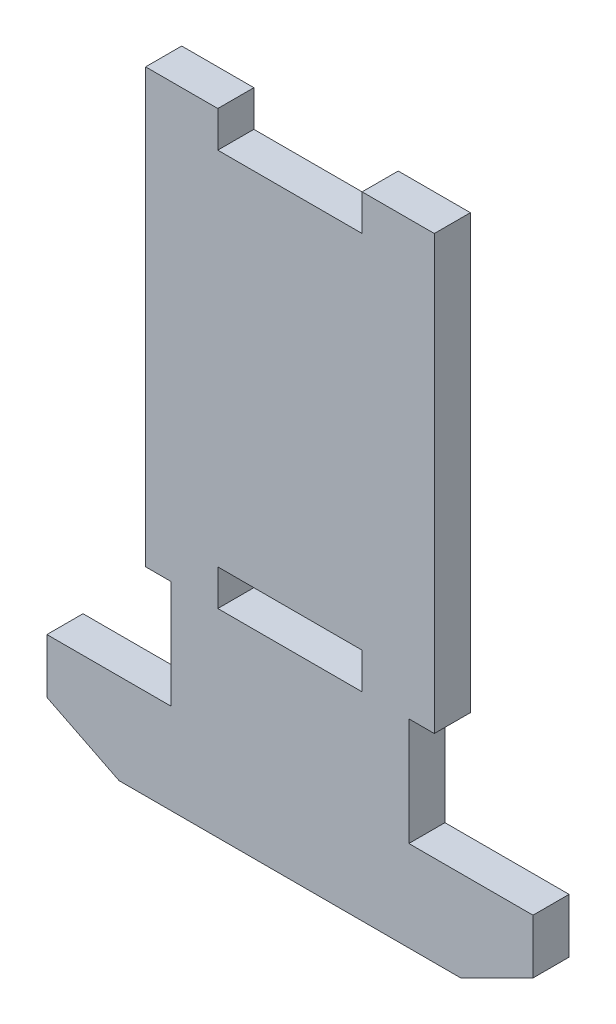
from build123d import *

# Parameters (mm, degrees)
BOSS_EXTRUDE1_DEPTH = 3.175
SKETCH2_W           = 25.4
SKETCH2_H           = 17.4625
BOSS_EXTRUDE2_DEPTH = 3.175
SKETCH4_W           = 2.238000096
SKETCH4_H           = 9.5
CUT_EXTRUDE1_DEPTH  = 3.175
SKETCH5_W           = 8.68426
SKETCH5_H           = 7.9625
BOSS_EXTRUDE3_DEPTH = 3.175
CUT_EXTRUDE2_DEPTH  = 3.175


with BuildPart() as part:
    # Sketch1 → Boss-Extrude1 (new body)
    with BuildSketch(Plane.XY):
        Polygon((-12.7, 19.05), (-6.35, 19.05), (-6.35, 15.875), (6.35, 15.875), (6.35, 19.05), (12.7, 19.05), (12.7, -19.05), (6.35, -19.05), (6.35, -15.875), (-6.35, -15.875), (-6.35, -19.05), (-12.7, -19.05), align=None)
    extrude(amount=BOSS_EXTRUDE1_DEPTH)

    # Sketch2 → Boss-Extrude2 (add)
    with BuildSketch(Plane(origin=(0, 0, 0), x_dir=(-1, 0, 0), z_dir=(0, 0, -1))):
        with Locations((0, -27.78125)):
            Rectangle(SKETCH2_W, SKETCH2_H)
    extrude(amount=-BOSS_EXTRUDE2_DEPTH)

    # Sketch4 → Cut-Extrude1 (cut)
    with BuildSketch(Plane(origin=(0, 0, 0), x_dir=(-1, 0, 0), z_dir=(0, 0, -1))):
        with Locations((-11.580999952, -23.8)):
            Rectangle(SKETCH4_W, SKETCH4_H)
    cut_extrude1 = extrude(amount=-CUT_EXTRUDE1_DEPTH, mode=Mode.SUBTRACT)

    # Sketch5 → Boss-Extrude3 (add)
    with BuildSketch(Plane(origin=(0, 0, 0), x_dir=(-1, 0, 0), z_dir=(0, 0, -1))):
        with Locations((-17.04213, -32.53125)):
            Rectangle(SKETCH5_W, SKETCH5_H)
    boss_extrude3 = extrude(amount=-BOSS_EXTRUDE3_DEPTH)

    # Sketch6 → Cut-Extrude2 (cut)
    with BuildSketch(Plane(origin=(0, 0, 0), x_dir=(-1, 0, 0), z_dir=(0, 0, -1))):
        Polygon((-21.38426, -33.3375), (-15.03426, -36.5125), (-21.38426, -36.5125), align=None)
    cut_extrude2 = extrude(amount=-CUT_EXTRUDE2_DEPTH, mode=Mode.SUBTRACT)

    # Mirror1: Cut-Extrude1, Boss-Extrude3, Cut-Extrude2 across plane
    add(cut_extrude1.mirror(Plane(origin=(0, 0, 0), x_dir=(0, 0, 1), z_dir=(1, 0, 0))), mode=Mode.SUBTRACT)
    add(boss_extrude3.mirror(Plane(origin=(0, 0, 0), x_dir=(0, 0, 1), z_dir=(1, 0, 0))))
    add(cut_extrude2.mirror(Plane(origin=(0, 0, 0), x_dir=(0, 0, 1), z_dir=(1, 0, 0))), mode=Mode.SUBTRACT)


solid = part.part
